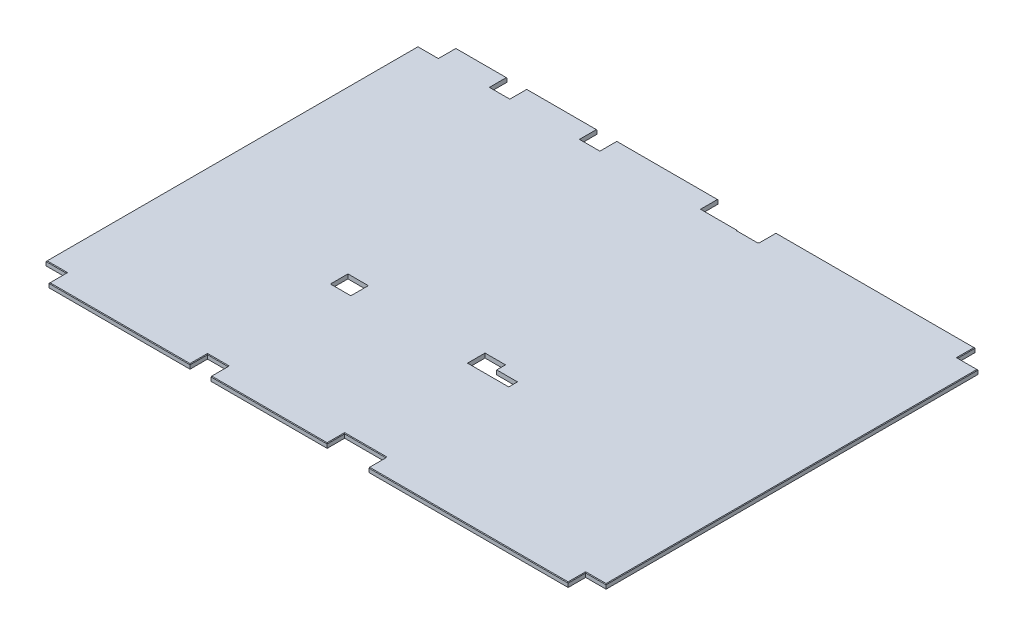
from build123d import *

# Parameters (mm, degrees)
SKETCH1_W           = 2438.4
SKETCH1_H           = 1771.65
BOSS_EXTRUDE1_DEPTH = 9.525
SKETCH2_W           = 88.9
SKETCH2_H           = 76.2
SKETCH2_W_2         = 177.8
CUT_EXTRUDE1_DEPTH  = 20.05
CHAMFER1_SIZE       = 2.54
SKETCH4_W           = 88.9
SKETCH4_H           = 76.2
CUT_EXTRUDE2_DEPTH  = 20.05
SKETCH5_W           = 88.9
SKETCH5_H           = 76.2
SKETCH5_W_2         = 254.7239
SKETCH5_W_3         = 92.1004
SKETCH5_W_4         = 179.3875
CUT_EXTRUDE3_DEPTH  = 20.05


with BuildPart() as part:
    # Sketch1 → Boss-Extrude1 (new body, symmetric)
    with BuildSketch(Plane(origin=(0, 0, 0), x_dir=(1, 0, 0), z_dir=(0, 1, 0))):
        with Locations((1219.2, 885.825)):
            Rectangle(SKETCH1_W, SKETCH1_H)
    extrude(amount=BOSS_EXTRUDE1_DEPTH, both=True)

    # Sketch2 → Cut-Extrude1 (cut, through all)
    with BuildSketch(Plane(origin=(0, 9.525, 0), x_dir=(1, 0, 0), z_dir=(0, 1, 0))):
        with Locations((1435.1127, 1733.55)):
            Rectangle(SKETCH2_W, SKETCH2_H)
        with Locations((44.45, 1733.55)):
            Rectangle(SKETCH2_W, SKETCH2_H)
        with Locations((2393.95, 1733.55)):
            Rectangle(SKETCH2_W, SKETCH2_H)
        with Locations((1389.0752, 38.1)):
            Rectangle(SKETCH2_W_2, SKETCH2_H)
        with Locations((747.7252, 38.1)):
            Rectangle(SKETCH2_W, SKETCH2_H)
        with Locations((2393.95, 38.1)):
            Rectangle(SKETCH2_W, SKETCH2_H)
        with Locations((44.45, 38.1)):
            Rectangle(SKETCH2_W, SKETCH2_H)
    extrude(amount=-CUT_EXTRUDE1_DEPTH, mode=Mode.SUBTRACT)

    # Chamfer1
    chamfer1_edges = [part.edges().sort_by_distance(p)[0] for p in [
        (0, 9.525, -885.825),
        (396.0876, 9.525, 0),
        (1046.1752, 9.525, 0),
        (1913.7376, 9.525, 0),
        (2438.4, 9.525, -885.825),
        (1914.53135, 9.525, -1771.65),
        (739.78135, 9.525, -1771.65),
        (2393.95, 9.525, -76.2),
        (2349.5, 9.525, -38.1),
        (792.1752, 9.525, -38.1),
        (747.7252, 9.525, -76.2),
        (703.2752, 9.525, -38.1),
        (1477.9752, 9.525, -38.1),
        (1389.0752, 9.525, -76.2),
        (1300.1752, 9.525, -38.1),
        (2349.5, 9.525, -1733.55),
        (2393.95, 9.525, -1695.45),
        (1390.6627, 9.525, -1733.55),
        (1435.1127, 9.525, -1695.45),
        (1479.5627, 9.525, -1733.55),
        (88.9, 9.525, -38.1),
        (44.45, 9.525, -76.2),
        (44.45, 9.525, -1695.45),
        (88.9, 9.525, -1733.55),
    ]]
    chamfer(chamfer1_edges, length=CHAMFER1_SIZE)

    # Sketch4 → Cut-Extrude2 (cut, through all)
    with BuildSketch(Plane(origin=(0, 9.525, 0), x_dir=(1, 0, 0), z_dir=(0, 1, 0))):
        with Locations((355.6, 1733.55)):
            Rectangle(SKETCH4_W, SKETCH4_H)
        with Locations((1274.7752, 1733.55)):
            Rectangle(SKETCH4_W, SKETCH4_H)
    extrude(amount=-CUT_EXTRUDE2_DEPTH, mode=Mode.SUBTRACT)

    # Sketch5 → Cut-Extrude3 (cut, through all)
    with BuildSketch(Plane(origin=(0, 9.525, 0), x_dir=(1, 0, 0), z_dir=(0, 1, 0))):
        with Locations((44.45, 1733.55)):
            Rectangle(SKETCH5_W, SKETCH5_H)
        with Locations((355.6, 1733.55)):
            Rectangle(SKETCH5_W, SKETCH5_H)
        with Locations((747.7506, 1733.55)):
            Rectangle(SKETCH5_W, SKETCH5_H)
        with Locations((1357.68715, 1733.55)):
            Rectangle(SKETCH5_W_2, SKETCH5_H)
        with Locations((2393.95, 1733.55)):
            Rectangle(SKETCH5_W, SKETCH5_H)
        with Locations((750.9256, 646.112499999)):
            Rectangle(SKETCH5_W, SKETCH5_H)
        Polygon((1303.3756, 684.225199999), (1392.367165563, 684.225199999), (1392.367165563, 646.125199999), (1482.7631, 646.125199999), (1482.7631, 608.025199999), (1303.3756, 608.025199999), align=None)
        with Locations((44.45, 38.1)):
            Rectangle(SKETCH5_W, SKETCH5_H)
        with Locations((749.3254, 38.1)):
            Rectangle(SKETCH5_W_3, SKETCH5_H)
        with Locations((1393.06935, 38.1)):
            Rectangle(SKETCH5_W_4, SKETCH5_H)
        with Locations((2393.95, 38.1)):
            Rectangle(SKETCH5_W, SKETCH5_H)
    extrude(amount=-CUT_EXTRUDE3_DEPTH, mode=Mode.SUBTRACT)


solid = part.part
